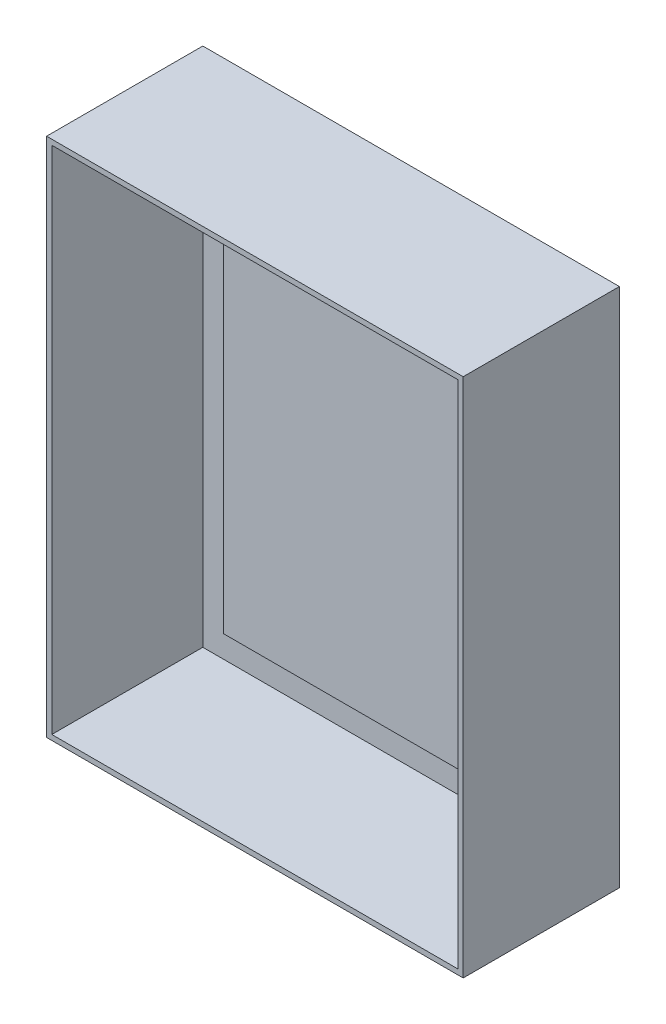
from build123d import *

# Parameters (mm, degrees)
SKETCH1_W           = 406.4
SKETCH1_H           = 508
BOSS_EXTRUDE1_DEPTH = 152.4
SHELL1_T            = -5.08
SKETCH2_W           = 350.52
SKETCH2_H           = 449.58
BOSS_EXTRUDE2_DEPTH = 2.54


with BuildPart() as part:
    # Sketch1 → Boss-Extrude1 (new body)
    with BuildSketch(Plane.XY):
        Rectangle(SKETCH1_W, SKETCH1_H)
    extrude(amount=BOSS_EXTRUDE1_DEPTH)

    # Shell1
    shell1_openings = [part.faces().sort_by_distance(p)[0] for p in [
        (0, 0, 152.4),
    ]]
    offset(amount=SHELL1_T, openings=shell1_openings, kind=Kind.INTERSECTION)

    # Sketch2 → Boss-Extrude2 (add)
    with BuildSketch(Plane.XY.offset(5.08)):
        Rectangle(SKETCH2_W, SKETCH2_H)
    extrude(amount=BOSS_EXTRUDE2_DEPTH)


solid = part.part
